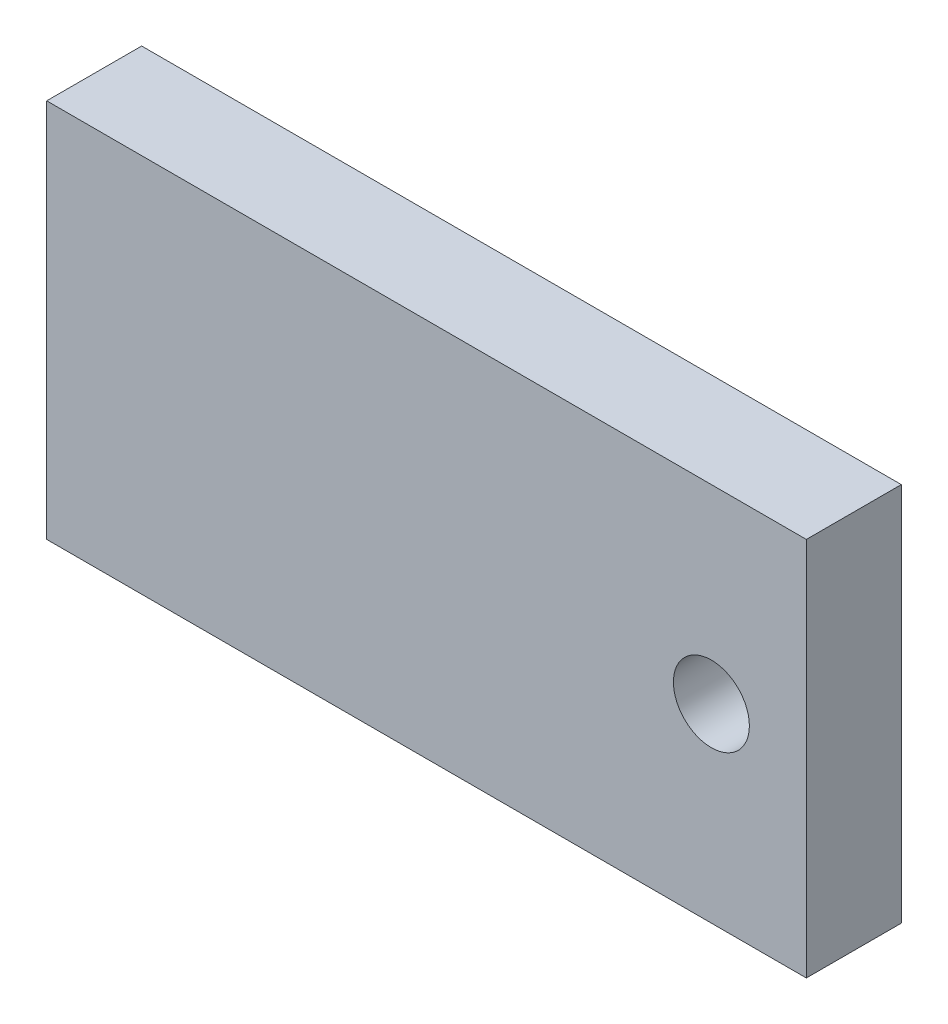
from build123d import *

# Parameters (mm, degrees)
SKETCH_1_R      = 2
EXTRUDE_1_DEPTH = 5


with BuildPart() as part:
    # 草图1 → 凸台-拉伸1 (new body)
    with BuildSketch(Plane.XY):
        Polygon((-29.300676155, 22.6111722), (-29.300676155, 2.6111722), (0.699323845, 2.6111722), (10.699323845, 2.6111722), (10.699323845, 22.6111722), align=None)
        with Locations((5.699323845, 12.6111722)):
            Circle(SKETCH_1_R, mode=Mode.SUBTRACT)
    extrude(amount=EXTRUDE_1_DEPTH)


solid = part.part
